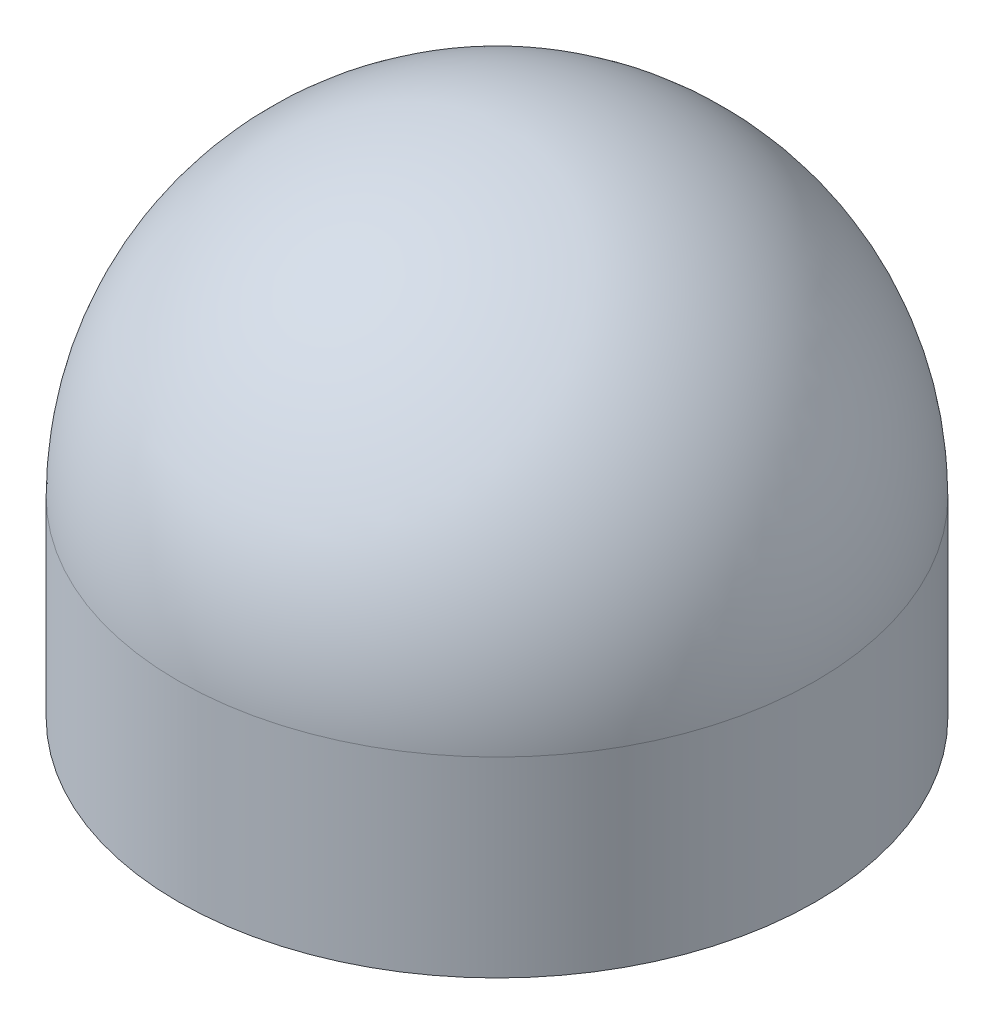
from build123d import *

# Parameters (mm, degrees)
SKETCH1_R           = 1.5
BOSS_EXTRUDE1_DEPTH = 0.9
DOME1_FACE_RADIUS   = 1.5
DOME1_HEIGHT        = 1.5


with BuildPart() as part:
    # Sketch1 → Boss-Extrude1 (new body)
    with BuildSketch(Plane(origin=(0, 0, 0), x_dir=(1, 0, 0), z_dir=(0, 1, 0))):
        Circle(SKETCH1_R)
    extrude(amount=BOSS_EXTRUDE1_DEPTH)

    # Dome1: a dome of height H over a round flat face of radius A is a cap of a sphere of radius (A * A + H * H) / (2 * H)
    dome1_r = (DOME1_FACE_RADIUS * DOME1_FACE_RADIUS + DOME1_HEIGHT * DOME1_HEIGHT) / (2 * DOME1_HEIGHT)
    dome1_base = Plane((0, 0.9, 0), z_dir=(0, 1, 0))
    with Locations(dome1_base.offset(DOME1_HEIGHT - dome1_r)):
        dome1_ball = Sphere(dome1_r, mode=Mode.PRIVATE)
    add(split(dome1_ball, bisect_by=dome1_base, keep=Keep.TOP, mode=Mode.PRIVATE))


solid = part.part
